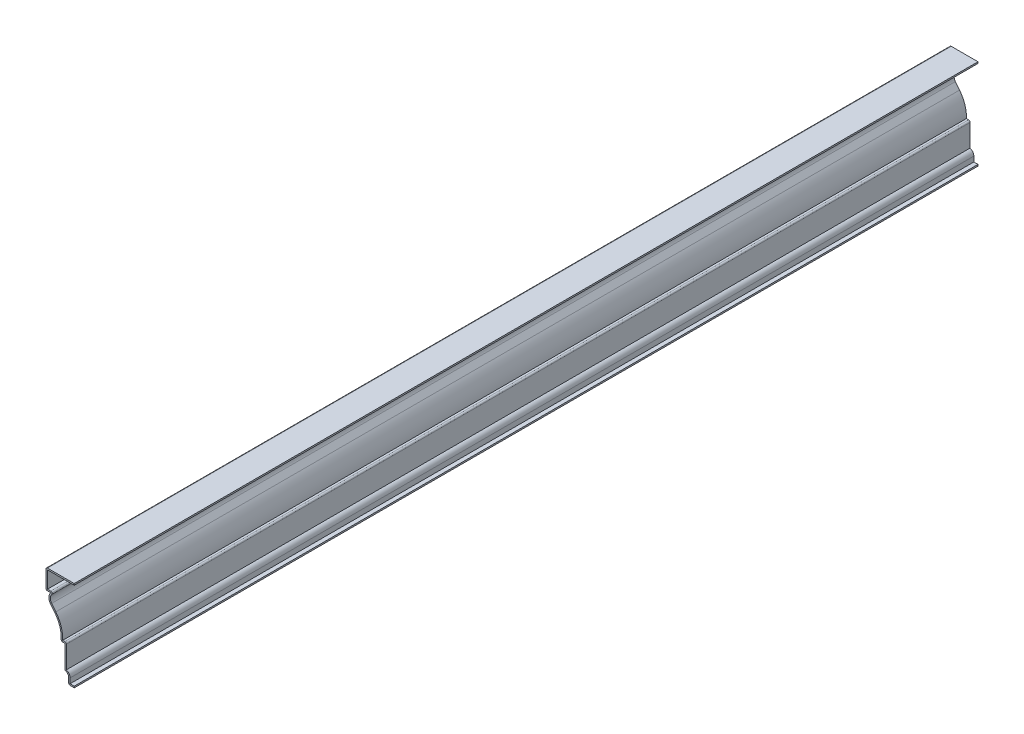
from build123d import *

# Parameters (mm, degrees)
BOSS_EXTRUDE2_DEPTH = 762
FILLET2_R           = 1.27


with BuildPart() as part:
    # Sketch1 → Boss-Extrude2 (new body)
    with BuildSketch(Plane.XY):
        with BuildLine():
            Line((0, 0), (-4.7625, 0))
            Line((-4.7625, 0), (-4.7625, 5.55625))
            ThreePointArc((-4.7625, 5.55625), (-5.69243597, 7.80131403), (-7.9375, 8.73125))
            Line((-7.9375, 8.73125), (-7.9375, 28.575))
            Line((-7.9375, 28.575), (-11.1125, 28.575))
            ThreePointArc((-11.1125, 28.575), (-12.019610958, 38.289886849), (-16.522183488, 46.946024405))
            Line((-16.522183488, 46.946024405), (-20.049007231, 51.371088071))
            ThreePointArc((-20.049007231, 51.371088071), (-21.43125, 55.488518856), (-19.84375, 59.53125))
            Line((-19.84375, 59.53125), (-23.8125, 59.53125))
            Line((-23.8125, 59.53125), (-23.8125, 76.2))
            Line((-23.8125, 76.2), (0, 76.2))
            Line((0, 76.2), (0, 74.93))
            Line((0, 74.93), (-22.5425, 74.93))
            Line((-22.5425, 74.93), (-22.5425, 60.80125))
            Line((-22.5425, 60.80125), (-19.84375, 60.80125))
            ThreePointArc((-19.84375, 60.80125), (-18.686099129, 60.053499423), (-18.891651575, 58.690768834))
            ThreePointArc((-18.891651575, 58.690768834), (-20.161651575, 55.456583919), (-19.05585736, 52.162639291))
            Line((-19.05585736, 52.162639291), (-15.529033617, 47.737575625))
            ThreePointArc((-15.529033617, 47.737575625), (-11.00800601, 39.317919875), (-9.745436159, 29.845))
            Line((-9.745436159, 29.845), (-6.6675, 29.845))
            Line((-6.6675, 29.845), (-6.6675, 9.815959497))
            ThreePointArc((-6.6675, 9.815959497), (-4.373571339, 8.212645584), (-3.4925, 5.55625))
            Line((-3.4925, 5.55625), (-3.4925, 1.27))
            Line((-3.4925, 1.27), (0, 1.27))
            Line((0, 1.27), (0, 0))
        make_face()
    extrude(amount=-BOSS_EXTRUDE2_DEPTH)

    # Fillet2
    fillet2_edges = [part.edges().sort_by_distance(p)[0] for p in [
        (-6.6675, 29.845, -381),
        (-4.7625, 0, -381),
        (-7.9375, 8.73125, -381),
        (-11.1125, 28.575, -381),
        (-23.8125, 59.53125, -381),
        (-23.8125, 76.2, -381),
    ]]
    fillet(fillet2_edges, radius=FILLET2_R)


solid = part.part
